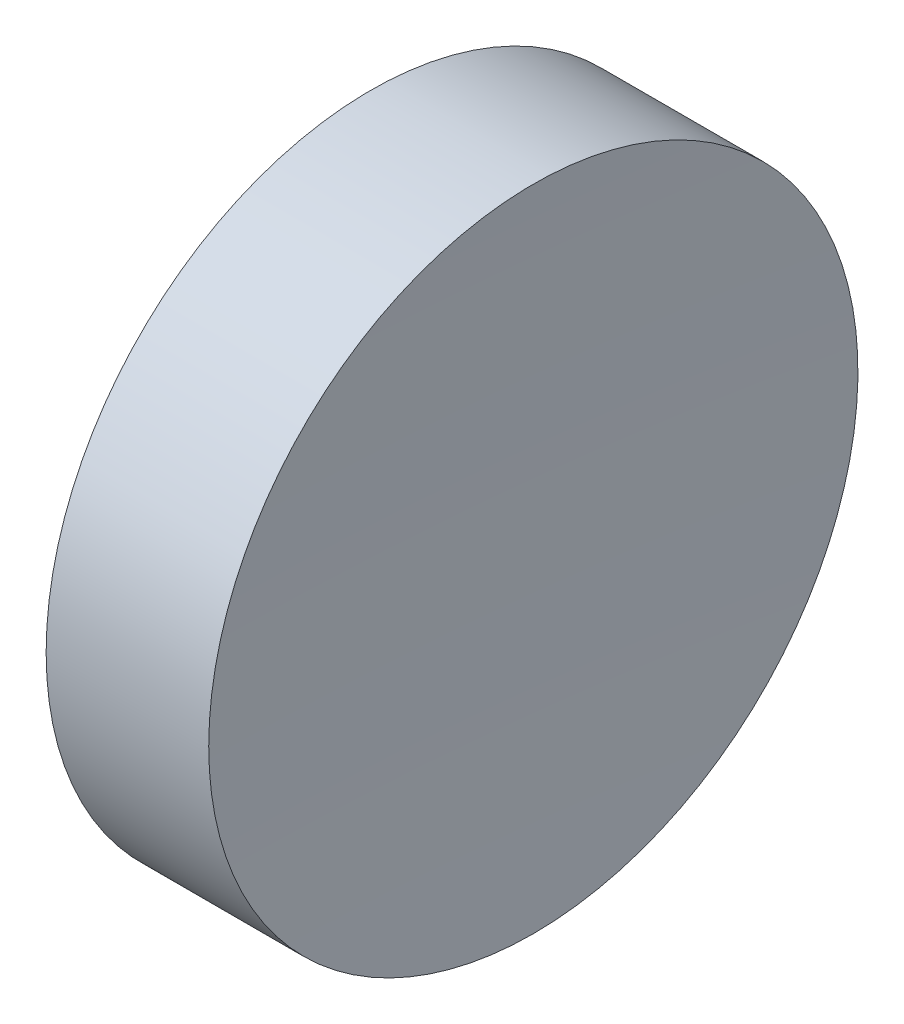
from build123d import *


with BuildPart() as part:
    # 草图1 → 旋转1 (revolve)
    with BuildSketch(Plane.XY, mode=Mode.PRIVATE) as revolve_1_sk:
        with BuildLine():
            Line((115.092655535, 69.378021123), (115.092655535, 81.878021123))
            Line((115.092655535, 81.878021123), (121.353185309, 81.878021123))
            ThreePointArc((121.353185309, 81.878021123), (121.157795036, 75.629378491), (121.092655516, 69.378021123))
            Line((121.092655516, 69.378021123), (115.092655535, 69.378021123))
        make_face()
    revolve(revolve_1_sk.sketch.rotate(Axis((108.985143002, 69.378021123, 0), (1, 0, 0)), 180), axis=Axis((108.985143002, 69.378021123, 0), (1, 0, 0)))  # turned: the seam where the file's is


solid = part.part
